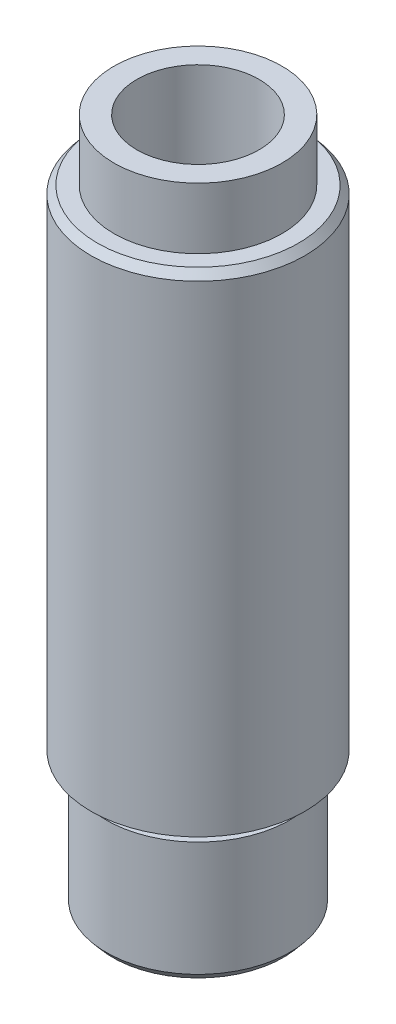
from build123d import *

# Parameters (mm, degrees)
CROQUIS1_R              = 7
CROQUIS1_R_2            = 4
SALIENTE_EXTRUIR1_DEPTH = 32
CROQUIS2_R              = 4
SALIENTE_EXTRUIR2_DEPTH = 3
CROQUIS3_R              = 5.5
SALIENTE_EXTRUIR3_DEPTH = 1
CROQUIS4_R              = 6
SALIENTE_EXTRUIR4_DEPTH = 8
CROQUIS5_R              = 2
CORTAR_EXTRUIR1_DEPTH   = 34
CHAFL_N1_SIZE           = 3
CHAFL_N1_SIZE2          = 2.100622615
CHAFL_N2_SIZE           = 0.5
CHAFL_N2_SIZE2          = 0.419549816
CHAFL_N3_SIZE           = 0.5
CHAFL_N3_SIZE2          = 0.419549816
CROQUIS6_R              = 5.5
CROQUIS6_R_2            = 4
SALIENTE_EXTRUIR5_DEPTH = 4


with BuildPart() as part:
    # Croquis1 → Saliente-Extruir1 (new body)
    with BuildSketch(Plane(origin=(0, 0, 0), x_dir=(1, 0, 0), z_dir=(0, 1, 0))):
        Circle(CROQUIS1_R)
        Circle(CROQUIS1_R_2, mode=Mode.SUBTRACT)
    extrude(amount=SALIENTE_EXTRUIR1_DEPTH)

    # Croquis2 → Saliente-Extruir2 (add)
    with BuildSketch(Plane(origin=(0, 3, 0), x_dir=(1, 0, 0), z_dir=(0, 1, 0))):
        Circle(CROQUIS2_R)
    extrude(amount=-SALIENTE_EXTRUIR2_DEPTH)

    # Croquis3 → Saliente-Extruir3 (add)
    with BuildSketch(Plane(origin=(0, 0, 0), x_dir=(-1, 0, 0), z_dir=(0, -1, 0))):
        Circle(CROQUIS3_R)
    extrude(amount=SALIENTE_EXTRUIR3_DEPTH)

    # Croquis4 → Saliente-Extruir4 (add)
    with BuildSketch(Plane.XZ.offset(1)):
        Circle(CROQUIS4_R)
    extrude(amount=SALIENTE_EXTRUIR4_DEPTH)

    # Croquis5 → Cortar-Extruir1 (cut)
    with BuildSketch(Plane.XZ.offset(9)):
        Circle(CROQUIS5_R)
    extrude(amount=-CORTAR_EXTRUIR1_DEPTH, mode=Mode.SUBTRACT)

    # Chaflán1
    chafl_n1_edges = [part.edges().sort_by_distance(p)[0] for p in [
        (-2, -9, 0),
    ]]
    chafl_n1_side = [part.faces().sort_by_distance(p)[0] for p in [
        (-5.830294373, -9, 0),
    ]]
    chamfer(chafl_n1_edges, length=CHAFL_N1_SIZE, length2=CHAFL_N1_SIZE2, reference=chafl_n1_side[0])

    # Chaflán2
    chafl_n2_edges = [part.edges().sort_by_distance(p)[0] for p in [
        (-6, -9, 0),
    ]]
    chafl_n2_side = [part.faces().sort_by_distance(p)[0] for p in [
        (-6, -5, 0),
    ]]
    chamfer(chafl_n2_edges, length=CHAFL_N2_SIZE, length2=CHAFL_N2_SIZE2, reference=chafl_n2_side[0])

    # Chaflán3
    chafl_n3_edges = [part.edges().sort_by_distance(p)[0] for p in [
        (-7, 32, 0),
    ]]
    chafl_n3_side = [part.faces().sort_by_distance(p)[0] for p in [
        (-7, 16, 0),
    ]]
    chamfer(chafl_n3_edges, length=CHAFL_N3_SIZE, length2=CHAFL_N3_SIZE2, reference=chafl_n3_side[0])

    # Croquis6 → Saliente-Extruir5 (add)
    with BuildSketch(Plane(origin=(0, 32, 0), x_dir=(1, 0, 0), z_dir=(0, 1, 0))):
        Circle(CROQUIS6_R)
        Circle(CROQUIS6_R_2, mode=Mode.SUBTRACT)
    extrude(amount=SALIENTE_EXTRUIR5_DEPTH)


solid = part.part
